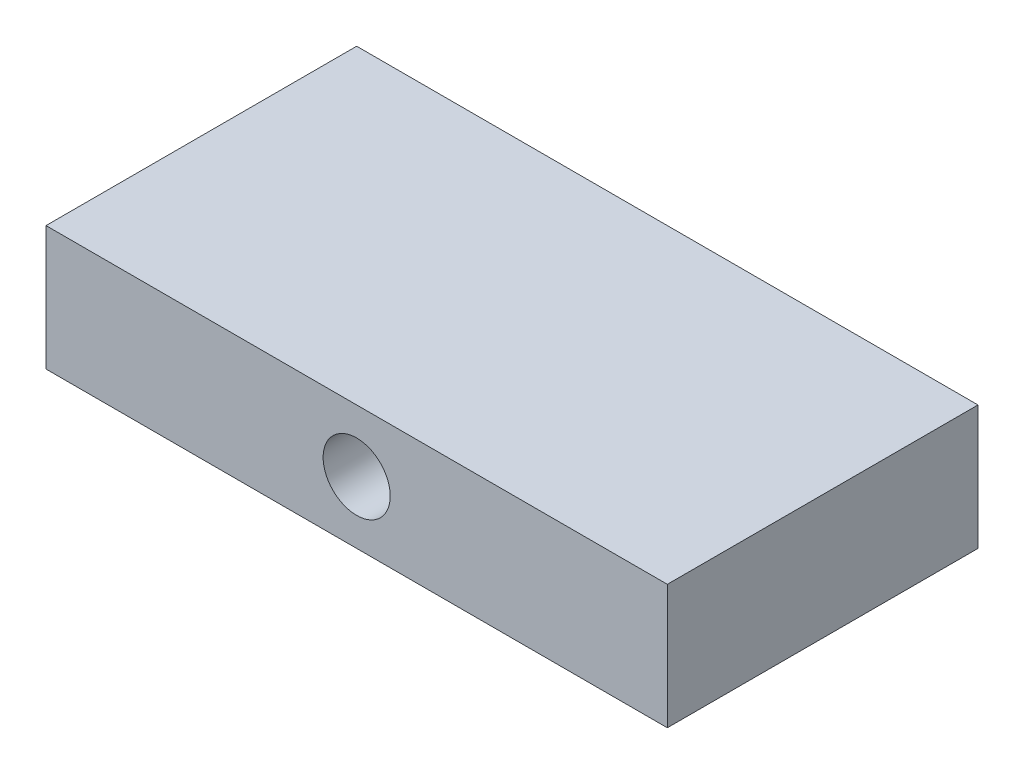
from build123d import *

# Parameters (mm, degrees)
SKETCH1_W           = 127
SKETCH1_H           = 63.5
BOSS_EXTRUDE1_DEPTH = 25.4
SKETCH2_R           = 6.858
CUT_EXTRUDE1_DEPTH  = 19.05
SKETCH3_R           = 6.858
CUT_EXTRUDE2_DEPTH  = 19.05


with BuildPart() as part:
    # Sketch1 → Boss-Extrude1 (new body)
    with BuildSketch(Plane(origin=(0, 0, 0), x_dir=(1, 0, 0), z_dir=(0, 1, 0))):
        Rectangle(SKETCH1_W, SKETCH1_H)
    extrude(amount=BOSS_EXTRUDE1_DEPTH)

    # Sketch2 → Cut-Extrude1 (cut)
    with BuildSketch(Plane.XY.offset(31.75)):
        with Locations((0, 12.7)):
            Circle(SKETCH2_R)
    extrude(amount=-CUT_EXTRUDE1_DEPTH, mode=Mode.SUBTRACT)

    # Sketch3 → Cut-Extrude2 (cut)
    with BuildSketch(Plane(origin=(0, 0, -31.75), x_dir=(-1, 0, 0), z_dir=(0, 0, -1))):
        with Locations((25.4, 12.7)):
            Circle(SKETCH3_R)
        with Locations((-25.4, 12.7)):
            Circle(SKETCH3_R)
    extrude(amount=-CUT_EXTRUDE2_DEPTH, mode=Mode.SUBTRACT)


solid = part.part
